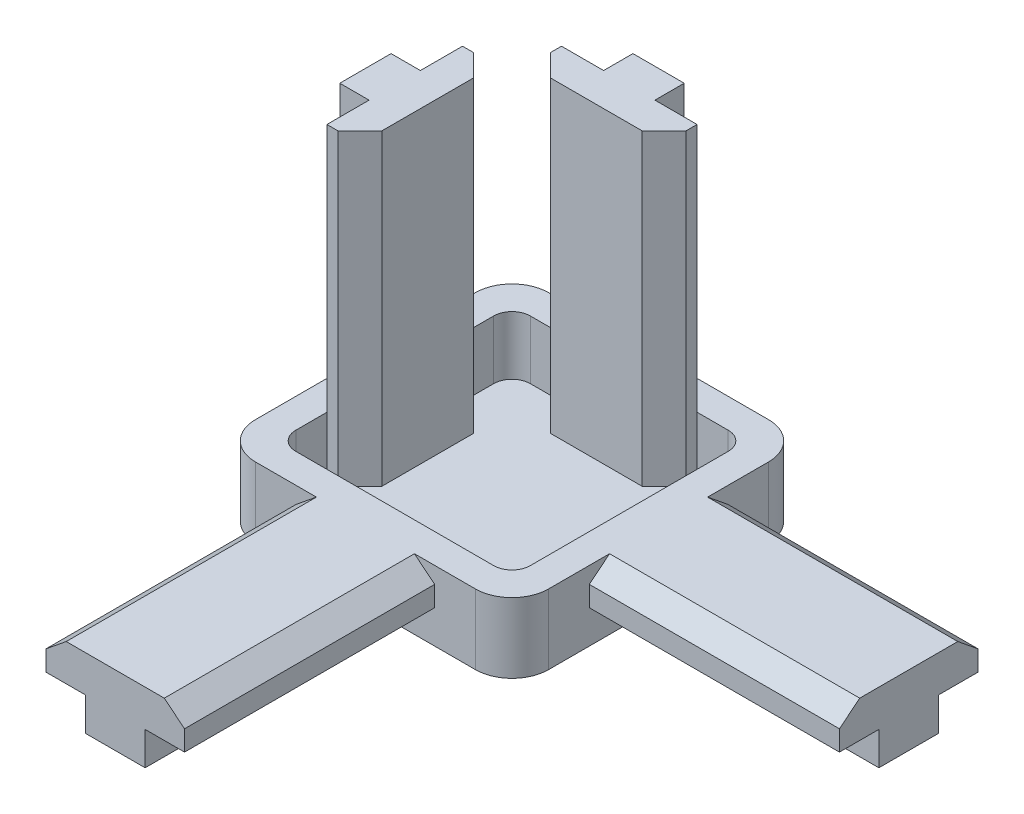
from build123d import *

# Parameters (mm, degrees)
SKETCH1_W           = 40
SKETCH1_H           = 40
BOSS_EXTRUDE2_DEPTH = 9.54
SKETCH2_W           = 32
SKETCH2_H           = 32
CUT_EXTRUDE1_DEPTH  = 8
BOSS_EXTRUDE3_DEPTH = 42
CIRPATTERN1_COUNT   = 2
CIRPATTERN1_ANGLE   = 90
BOSS_EXTRUDE4_DEPTH = 34.13
CIRPATTERN2_COUNT   = 2
CIRPATTERN2_ANGLE   = 90
FILLET1_R           = 2.5
FILLET2_R           = 5


with BuildPart() as part:
    # Sketch1 → Boss-Extrude2 (new body)
    with BuildSketch(Plane(origin=(0, 0, 0), x_dir=(1, 0, 0), z_dir=(0, 1, 0))):
        Rectangle(SKETCH1_W, SKETCH1_H)
    extrude(amount=BOSS_EXTRUDE2_DEPTH)

    # Sketch2 → Cut-Extrude1 (cut)
    with BuildSketch(Plane(origin=(0, 9.54, 0), x_dir=(1, 0, 0), z_dir=(0, 1, 0))):
        Rectangle(SKETCH2_W, SKETCH2_H)
    extrude(amount=-CUT_EXTRUDE1_DEPTH, mode=Mode.SUBTRACT)

    # Sketch3 → Boss-Extrude3 (add)
    with BuildSketch(Plane(origin=(0, 1.54, 0), x_dir=(1, 0, 0), z_dir=(0, 1, 0))):
        Polygon((3.5, 20), (-3.5, 20), (-3.5, 16), (-9.25, 16), (-9.25, 14.4844), (-6.2656, 11.5), (6.2656, 11.5), (9.25, 14.4844), (9.25, 16), (3.5, 16), align=None)
    boss_extrude3 = extrude(amount=BOSS_EXTRUDE3_DEPTH)

    # CirPattern1: Boss-Extrude3 ×2 about axis
    cirpattern1_axis = Axis((0, 0, 0), (0, 1, 0))
    for i in range(1, CIRPATTERN1_COUNT):
        add(boss_extrude3.rotate(cirpattern1_axis, i * CIRPATTERN1_ANGLE / (CIRPATTERN1_COUNT - 1)))

    # Sketch4 → Boss-Extrude4 (add)
    with BuildSketch(Plane.XY.offset(20)):
        Polygon((-4.075, 0), (4.075, 0), (4.075, 4.54), (9.45, 4.54), (9.45, 7.3), (6.689745603, 9.54), (-6.689745603, 9.54), (-9.45, 7.3), (-9.45, 4.54), (-4.075, 4.54), align=None)
    boss_extrude4 = extrude(amount=BOSS_EXTRUDE4_DEPTH)

    # CirPattern2: Boss-Extrude4 ×2 about axis
    cirpattern2_axis = Axis((0, 0, 0), (0, 1, 0))
    for i in range(1, CIRPATTERN2_COUNT):
        add(boss_extrude4.rotate(cirpattern2_axis, i * CIRPATTERN2_ANGLE / (CIRPATTERN2_COUNT - 1)))

    # Fillet1
    fillet1_edges = [part.edges().sort_by_distance(p)[0] for p in [
        (16, 5.54, -16),
        (16, 5.54, 16),
        (-16, 5.54, 16),
        (-16, 5.54, -16),
    ]]
    fillet(fillet1_edges, radius=FILLET1_R)

    # Fillet2
    fillet2_edges = [part.edges().sort_by_distance(p)[0] for p in [
        (20, 4.77, 20),
        (-20, 4.77, 20),
        (-20, 4.77, -20),
        (20, 4.77, -20),
    ]]
    fillet(fillet2_edges, radius=FILLET2_R)


solid = part.part
